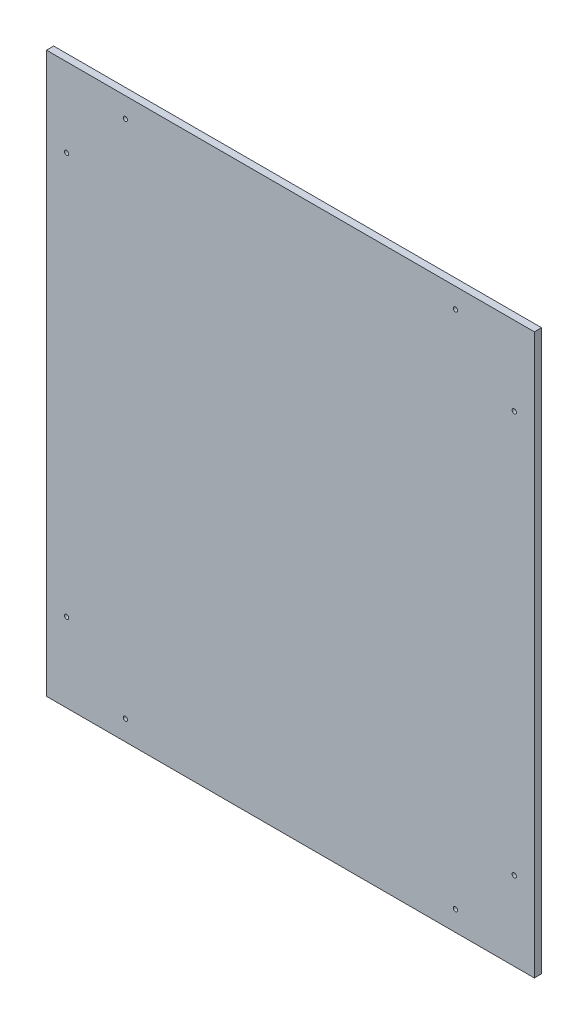
from build123d import *

# Parameters (mm, degrees)
CROQUIS1_W              = 340
CROQUIS1_H              = 390
CROQUIS1_R              = 1.5
SALIENTE_EXTRUIR1_DEPTH = 5


with BuildPart() as part:
    # Croquis1 → Saliente-Extruir1 (new body)
    with BuildSketch(Plane.XY):
        with Locations((108.94719541, -145.463974458)):
            Rectangle(CROQUIS1_W, CROQUIS1_H)
        with Locations((-47.05280459, -285.463974458)):
            Circle(CROQUIS1_R, mode=Mode.SUBTRACT)
        with Locations((264.94719541, -285.463974458)):
            Circle(CROQUIS1_R, mode=Mode.SUBTRACT)
        with Locations((264.94719541, -5.463974458)):
            Circle(CROQUIS1_R, mode=Mode.SUBTRACT)
        with Locations((-47.05280459, -5.463974458)):
            Circle(CROQUIS1_R, mode=Mode.SUBTRACT)
        with Locations((-6.05280459, -326.463974458)):
            Circle(CROQUIS1_R, mode=Mode.SUBTRACT)
        with Locations((223.94719541, -326.463974458)):
            Circle(CROQUIS1_R, mode=Mode.SUBTRACT)
        with Locations((223.94719541, 35.536025542)):
            Circle(CROQUIS1_R, mode=Mode.SUBTRACT)
        with Locations((-6.05280459, 35.536025542)):
            Circle(CROQUIS1_R, mode=Mode.SUBTRACT)
    extrude(amount=SALIENTE_EXTRUIR1_DEPTH)


solid = part.part
